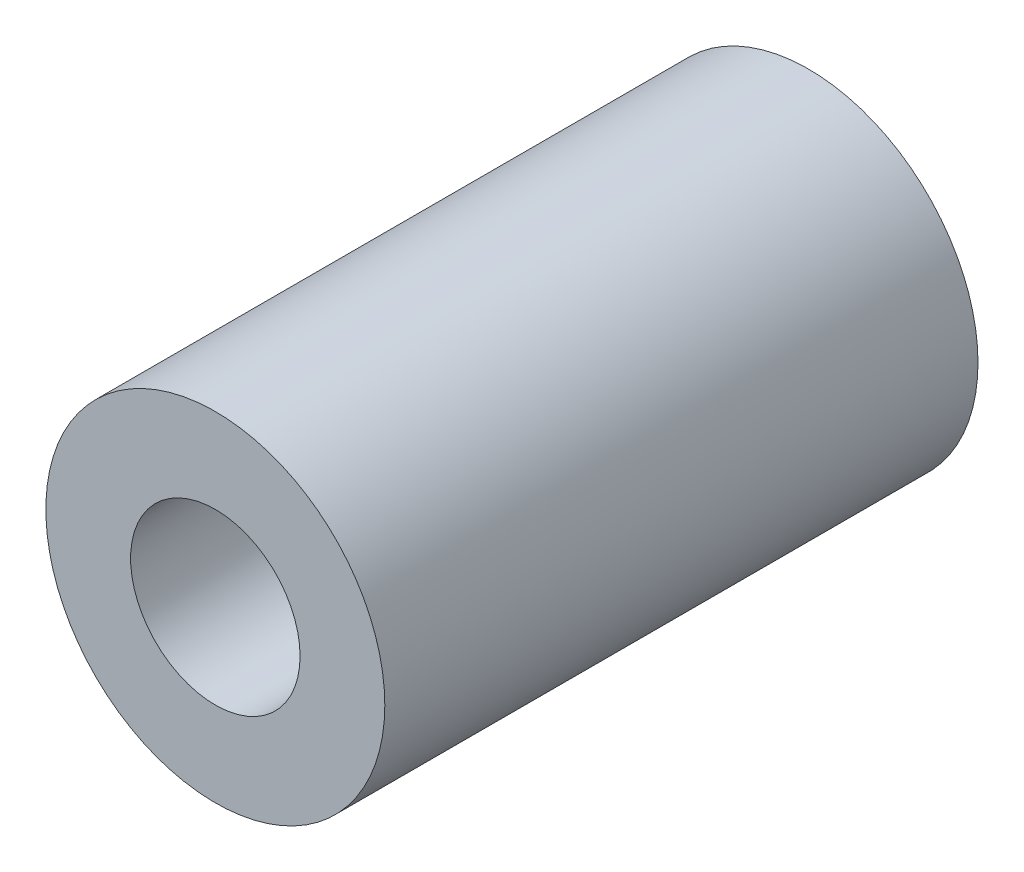
from build123d import *

# Parameters (mm, degrees)
ESQUISSE1_R        = 20
ESQUISSE1_R_2      = 10
BOSS_EXTRU_1_DEPTH = 35


with BuildPart() as part:
    # Esquisse1 → Boss.-Extru.1 (new body, symmetric)
    with BuildSketch(Plane.XY):
        Circle(ESQUISSE1_R)
        Circle(ESQUISSE1_R_2, mode=Mode.SUBTRACT)
    extrude(amount=BOSS_EXTRU_1_DEPTH, both=True)


solid = part.part
